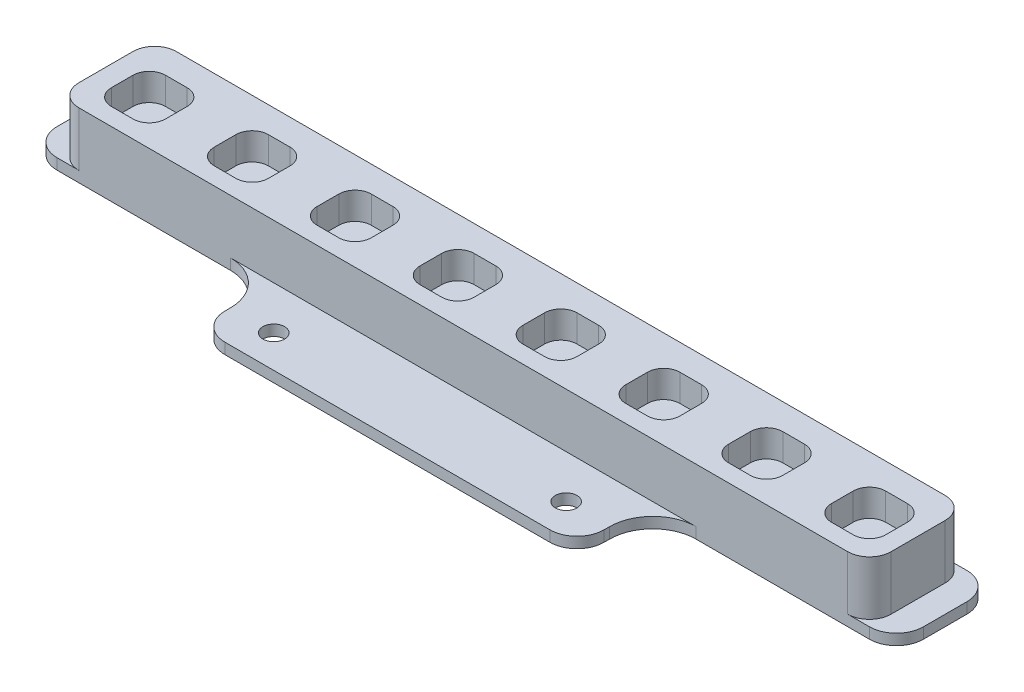
from build123d import *

# Parameters (mm, degrees)
SKETCH_1_R          = 2
EXTRUDE_1_DEPTH     = 2
EXTRUDE_2_DEPTH     = 10
CUT_EXTRUDE_1_DEPTH = 5


with BuildPart() as part:
    # 草图1 → 凸台-拉伸1 (new body)
    with BuildSketch(Plane(origin=(0, 0, 0), x_dir=(1, 0, 0), z_dir=(0, 1, 0))):
        with BuildLine():
            Line((-75, 32), (75, 32))
            ThreePointArc((75, 32), (78.535533906, 30.535533906), (80, 27))
            Line((80, 27), (80, 19))
            ThreePointArc((80, 19), (78.535533906, 15.464466094), (75, 14))
            Line((75, 14), (43, 14))
            ThreePointArc((43, 14), (37.343145751, 11.656854249), (35, 6))
            Line((35, 6), (35, 5))
            ThreePointArc((35, 5), (33.535533906, 1.464466094), (30, 0))
            Line((30, 0), (-30, 0))
            ThreePointArc((-30, 0), (-33.535533906, 1.464466094), (-35, 5))
            Line((-35, 5), (-35, 6))
            ThreePointArc((-35, 6), (-37.343145751, 11.656854249), (-43, 14))
            Line((-43, 14), (-75, 14))
            ThreePointArc((-75, 14), (-78.535533906, 15.464466094), (-80, 19))
            Line((-80, 19), (-80, 27))
            ThreePointArc((-80, 27), (-78.535533906, 30.535533906), (-75, 32))
        make_face()
        with Locations((-27, 6)):
            Circle(SKETCH_1_R, mode=Mode.SUBTRACT)
        with Locations((27, 6)):
            Circle(SKETCH_1_R, mode=Mode.SUBTRACT)
    extrude(amount=EXTRUDE_1_DEPTH)

    # 草图2 → 凸台-拉伸2 (add)
    with BuildSketch(Plane(origin=(0, 2, 0), x_dir=(1, 0, 0), z_dir=(0, 1, 0))):
        with BuildLine():
            Line((-71, 14), (71, 14))
            ThreePointArc((71, 14), (73.828427125, 15.171572875), (75, 18))
            Line((75, 18), (75, 28))
            ThreePointArc((75, 28), (73.828427125, 30.828427125), (71, 32))
            Line((71, 32), (-71, 32))
            ThreePointArc((-71, 32), (-73.828427125, 30.828427125), (-75, 28))
            Line((-75, 28), (-75, 18))
            ThreePointArc((-75, 18), (-73.828427125, 15.171572875), (-71, 14))
        make_face()
    extrude(amount=EXTRUDE_2_DEPTH)

    # 草图3 → 切除-拉伸1 (cut)
    with BuildSketch(Plane(origin=(0, 12, 0), x_dir=(1, 0, 0), z_dir=(0, 1, 0))):
        with BuildLine():
            Line((-49.200934141, 17.21130212), (-45.200934141, 17.21130212))
            ThreePointArc((-45.200934141, 17.21130212), (-43.079613798, 18.089981777), (-42.200934141, 20.21130212))
            Line((-42.200934141, 20.21130212), (-42.200934141, 24.21130212))
            ThreePointArc((-42.200934141, 24.21130212), (-43.079613798, 26.332622464), (-45.200934141, 27.21130212))
            Line((-45.200934141, 27.21130212), (-49.200934141, 27.21130212))
            ThreePointArc((-49.200934141, 27.21130212), (-51.322254485, 26.332622464), (-52.200934141, 24.21130212))
            Line((-52.200934141, 24.21130212), (-52.200934141, 20.21130212))
            ThreePointArc((-52.200934141, 20.21130212), (-51.322254485, 18.089981777), (-49.200934141, 17.21130212))
        make_face()
        with BuildLine():
            Line((-68.200934141, 17.21130212), (-64.200934141, 17.21130212))
            ThreePointArc((-64.200934141, 17.21130212), (-62.079613798, 18.089981777), (-61.200934141, 20.21130212))
            Line((-61.200934141, 20.21130212), (-61.200934141, 24.21130212))
            ThreePointArc((-61.200934141, 24.21130212), (-62.079613798, 26.332622464), (-64.200934141, 27.21130212))
            Line((-64.200934141, 27.21130212), (-68.200934141, 27.21130212))
            ThreePointArc((-68.200934141, 27.21130212), (-70.322254485, 26.332622464), (-71.200934141, 24.21130212))
            Line((-71.200934141, 24.21130212), (-71.200934141, 20.21130212))
            ThreePointArc((-71.200934141, 20.21130212), (-70.322254485, 18.089981777), (-68.200934141, 17.21130212))
        make_face()
        with BuildLine():
            Line((-30.200934141, 17.21130212), (-26.200934141, 17.21130212))
            ThreePointArc((-26.200934141, 17.21130212), (-24.079613798, 18.089981777), (-23.200934141, 20.21130212))
            Line((-23.200934141, 20.21130212), (-23.200934141, 24.21130212))
            ThreePointArc((-23.200934141, 24.21130212), (-24.079613798, 26.332622464), (-26.200934141, 27.21130212))
            Line((-26.200934141, 27.21130212), (-30.200934141, 27.21130212))
            ThreePointArc((-30.200934141, 27.21130212), (-32.322254485, 26.332622464), (-33.200934141, 24.21130212))
            Line((-33.200934141, 24.21130212), (-33.200934141, 20.21130212))
            ThreePointArc((-33.200934141, 20.21130212), (-32.322254485, 18.089981777), (-30.200934141, 17.21130212))
        make_face()
        with BuildLine():
            Line((-11.200934141, 17.21130212), (-7.200934141, 17.21130212))
            ThreePointArc((-7.200934141, 17.21130212), (-5.079613798, 18.089981777), (-4.200934141, 20.21130212))
            Line((-4.200934141, 20.21130212), (-4.200934141, 24.21130212))
            ThreePointArc((-4.200934141, 24.21130212), (-5.079613798, 26.332622464), (-7.200934141, 27.21130212))
            Line((-7.200934141, 27.21130212), (-11.200934141, 27.21130212))
            ThreePointArc((-11.200934141, 27.21130212), (-13.322254485, 26.332622464), (-14.200934141, 24.21130212))
            Line((-14.200934141, 24.21130212), (-14.200934141, 20.21130212))
            ThreePointArc((-14.200934141, 20.21130212), (-13.322254485, 18.089981777), (-11.200934141, 17.21130212))
        make_face()
        with BuildLine():
            Line((7.799065859, 17.21130212), (11.799065859, 17.21130212))
            ThreePointArc((11.799065859, 17.21130212), (13.920386202, 18.089981777), (14.799065859, 20.21130212))
            Line((14.799065859, 20.21130212), (14.799065859, 24.21130212))
            ThreePointArc((14.799065859, 24.21130212), (13.920386202, 26.332622464), (11.799065859, 27.21130212))
            Line((11.799065859, 27.21130212), (7.799065859, 27.21130212))
            ThreePointArc((7.799065859, 27.21130212), (5.677745515, 26.332622464), (4.799065859, 24.21130212))
            Line((4.799065859, 24.21130212), (4.799065859, 20.21130212))
            ThreePointArc((4.799065859, 20.21130212), (5.677745515, 18.089981777), (7.799065859, 17.21130212))
        make_face()
        with BuildLine():
            Line((26.799065859, 17.21130212), (30.799065859, 17.21130212))
            ThreePointArc((30.799065859, 17.21130212), (32.920386202, 18.089981777), (33.799065859, 20.21130212))
            Line((33.799065859, 20.21130212), (33.799065859, 24.21130212))
            ThreePointArc((33.799065859, 24.21130212), (32.920386202, 26.332622464), (30.799065859, 27.21130212))
            Line((30.799065859, 27.21130212), (26.799065859, 27.21130212))
            ThreePointArc((26.799065859, 27.21130212), (24.677745515, 26.332622464), (23.799065859, 24.21130212))
            Line((23.799065859, 24.21130212), (23.799065859, 20.21130212))
            ThreePointArc((23.799065859, 20.21130212), (24.677745515, 18.089981777), (26.799065859, 17.21130212))
        make_face()
        with BuildLine():
            Line((45.799065859, 17.21130212), (49.799065859, 17.21130212))
            ThreePointArc((49.799065859, 17.21130212), (51.920386202, 18.089981777), (52.799065859, 20.21130212))
            Line((52.799065859, 20.21130212), (52.799065859, 24.21130212))
            ThreePointArc((52.799065859, 24.21130212), (51.920386202, 26.332622464), (49.799065859, 27.21130212))
            Line((49.799065859, 27.21130212), (45.799065859, 27.21130212))
            ThreePointArc((45.799065859, 27.21130212), (43.677745515, 26.332622464), (42.799065859, 24.21130212))
            Line((42.799065859, 24.21130212), (42.799065859, 20.21130212))
            ThreePointArc((42.799065859, 20.21130212), (43.677745515, 18.089981777), (45.799065859, 17.21130212))
        make_face()
        with BuildLine():
            Line((64.799065859, 17.21130212), (68.799065859, 17.21130212))
            ThreePointArc((68.799065859, 17.21130212), (70.920386202, 18.089981777), (71.799065859, 20.21130212))
            Line((71.799065859, 20.21130212), (71.799065859, 24.21130212))
            ThreePointArc((71.799065859, 24.21130212), (70.920386202, 26.332622464), (68.799065859, 27.21130212))
            Line((68.799065859, 27.21130212), (64.799065859, 27.21130212))
            ThreePointArc((64.799065859, 27.21130212), (62.677745515, 26.332622464), (61.799065859, 24.21130212))
            Line((61.799065859, 24.21130212), (61.799065859, 20.21130212))
            ThreePointArc((61.799065859, 20.21130212), (62.677745515, 18.089981777), (64.799065859, 17.21130212))
        make_face()
    extrude(amount=-CUT_EXTRUDE_1_DEPTH, mode=Mode.SUBTRACT)


solid = part.part
